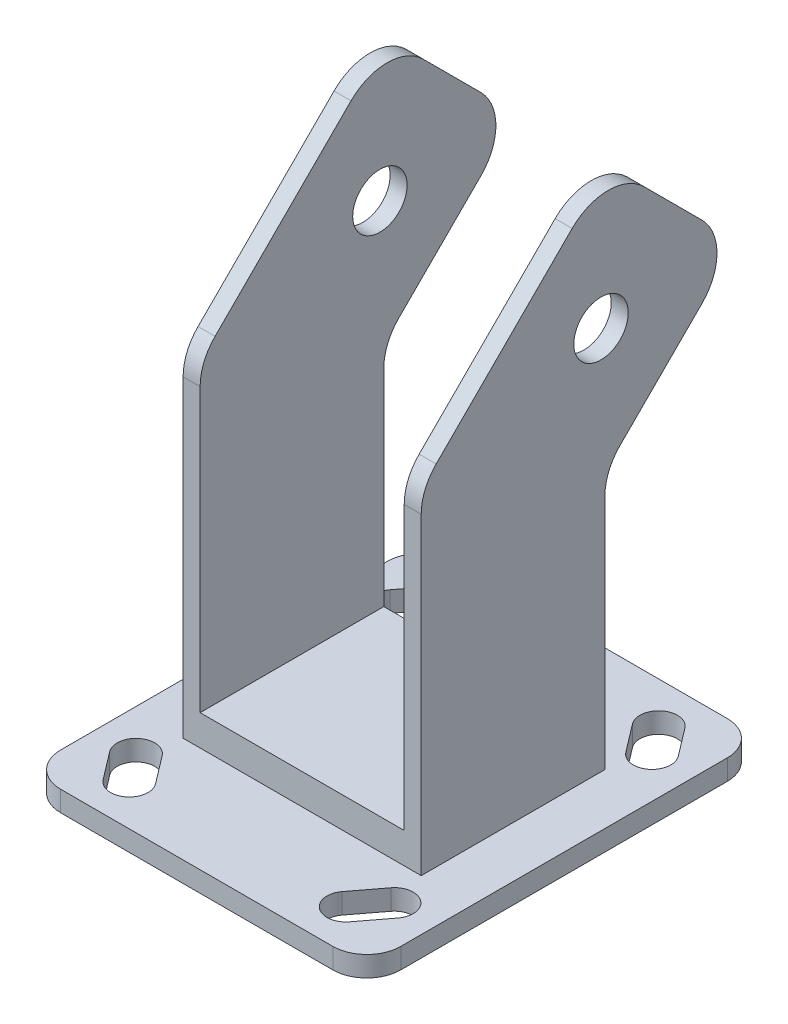
from build123d import *

# Parameters (mm, degrees)
SKETCH1_W           = 100
SKETCH1_H           = 116
BOSS_EXTRUDE1_DEPTH = 6
FILLET1_R           = 10
CUT_EXTRUDE1_DEPTH  = 6
SKETCH3_W           = 70
SKETCH3_H           = 54
BOSS_EXTRUDE2_DEPTH = 9
SKETCH5_R           = 8
BOSS_EXTRUDE3_DEPTH = 5


with BuildPart() as part:
    # Sketch1 → Boss-Extrude1 (new body)
    with BuildSketch(Plane(origin=(0, 0, 0), x_dir=(1, 0, 0), z_dir=(0, 1, 0))):
        Rectangle(SKETCH1_W, SKETCH1_H)
    extrude(amount=BOSS_EXTRUDE1_DEPTH)

    # Fillet1
    fillet1_edges = [part.edges().sort_by_distance(p)[0] for p in [
        (-50, 3, -58),
        (50, 3, -58),
        (50, 3, 58),
        (-50, 3, 58),
    ]]
    fillet(fillet1_edges, radius=FILLET1_R)

    # Sketch2 → Cut-Extrude1 (cut)
    with BuildSketch(Plane(origin=(0, 6, 0), x_dir=(1, 0, 0), z_dir=(0, 1, 0))):
        with BuildLine():
            Line((-36.189873482, 49.330370079), (-42.377057818, 41.198642095))
            ThreePointArc((-42.377057818, 41.198642095), (-41.330370079, 33.491214199), (-33.622942182, 34.537901938))
            Line((-33.622942182, 34.537901938), (-27.435757847, 42.669629921))
            ThreePointArc((-27.435757847, 42.669629921), (-28.482445586, 50.377057818), (-36.189873482, 49.330370079))
        make_face()
        with BuildLine():
            Line((36.189873482, 49.330370079), (42.377057818, 41.198642095))
            ThreePointArc((42.377057818, 41.198642095), (41.330370079, 33.491214199), (33.622942182, 34.537901938))
            Line((33.622942182, 34.537901938), (27.435757847, 42.669629921))
            ThreePointArc((27.435757847, 42.669629921), (28.482445586, 50.377057818), (36.189873482, 49.330370079))
        make_face()
        with BuildLine():
            Line((-36.189873482, -49.330370079), (-42.377057818, -41.198642095))
            ThreePointArc((-42.377057818, -41.198642095), (-41.330370079, -33.491214199), (-33.622942182, -34.537901938))
            Line((-33.622942182, -34.537901938), (-27.435757847, -42.669629921))
            ThreePointArc((-27.435757847, -42.669629921), (-28.482445586, -50.377057818), (-36.189873482, -49.330370079))
        make_face()
        with BuildLine():
            Line((36.189873482, -49.330370079), (42.377057818, -41.198642095))
            ThreePointArc((42.377057818, -41.198642095), (41.330370079, -33.491214199), (33.622942182, -34.537901938))
            Line((33.622942182, -34.537901938), (27.435757847, -42.669629921))
            ThreePointArc((27.435757847, -42.669629921), (28.482445586, -50.377057818), (36.189873482, -49.330370079))
        make_face()
    extrude(amount=-CUT_EXTRUDE1_DEPTH, mode=Mode.SUBTRACT)

    # Sketch3 → Boss-Extrude2 (add)
    with BuildSketch(Plane(origin=(0, 6, 0), x_dir=(1, 0, 0), z_dir=(0, 1, 0))):
        Rectangle(SKETCH3_W, SKETCH3_H)
    extrude(amount=BOSS_EXTRUDE2_DEPTH)

    # Sketch5 → Boss-Extrude3 (add)
    with BuildSketch(Plane.ZY.offset(35)):
        with BuildLine():
            Line((-27, 15), (27, 15))
            Line((27, 15), (27, 98.014328933))
            ThreePointArc((27, 98.014328933), (25.858192988, 103.754580418), (22.606601718, 108.62093065))
            Line((22.606601718, 108.62093065), (-17.36920564, 148.596738008))
            ThreePointArc((-17.36920564, 148.596738008), (-27.975807358, 152.990136291), (-38.582409076, 148.596738008))
            Line((-38.582409076, 148.596738008), (-55.552971824, 131.62617526))
            ThreePointArc((-55.552971824, 131.62617526), (-59.946370107, 121.019573542), (-55.552971824, 110.412971824))
            Line((-55.552971824, 110.412971824), (-31.393398282, 86.253398282))
            ThreePointArc((-31.393398282, 86.253398282), (-28.141807012, 81.38704805), (-27, 75.646796564))
            Line((-27, 75.646796564), (-27, 15))
        make_face()
        with Locations((-25.854487014, 118.898253199)):
            Circle(SKETCH5_R, mode=Mode.SUBTRACT)
    boss_extrude3 = extrude(amount=-BOSS_EXTRUDE3_DEPTH)

    # Mirror1: Boss-Extrude3 across plane
    add(boss_extrude3.mirror(Plane(origin=(0, 0, 0), x_dir=(0, 0, 1), z_dir=(1, 0, 0))))


solid = part.part
